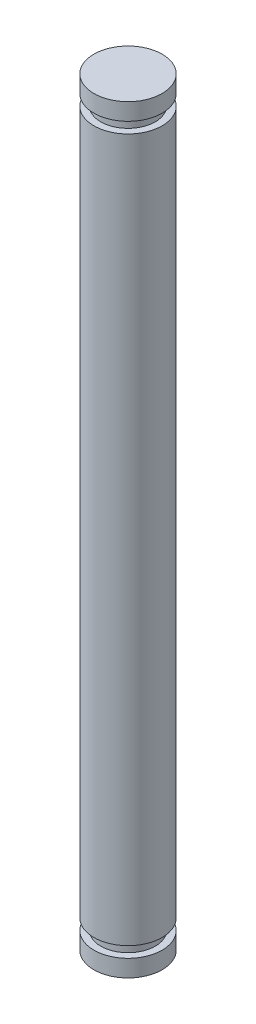
from build123d import *

# Parameters (mm, degrees)
SKETCH1_W   = 2
SKETCH1_H   = 44.5
ESQUISSE1_W = 0.574838605
ESQUISSE1_H = 0.64
ESQUISSE3_W = 1.093459546
ESQUISSE3_H = 0.64


with BuildPart() as part:
    # Sketch1 → Revolve1 (revolve)
    with BuildSketch(Plane.XY):
        with Locations((1, 22.25)):
            Rectangle(SKETCH1_W, SKETCH1_H)
    revolve(axis=Axis((0, 0, 0), (0, 1, 0)))

    # Esquisse1 → Enlèvement de matière-Révolution1 (revolve, cut)
    with BuildSketch(Plane.XY):
        with Locations((1.887419303, 43.18)):
            Rectangle(ESQUISSE1_W, ESQUISSE1_H)
    revolve(axis=Axis((0, 44.5, 0), (0, -1, 0)), mode=Mode.SUBTRACT)

    # Esquisse3 → Enlèvement de matière-Révolution3 (revolve, cut)
    with BuildSketch(Plane.XY):
        with Locations((2.146729773, 1.32)):
            Rectangle(ESQUISSE3_W, ESQUISSE3_H)
    revolve(axis=Axis((0, 44.5, 0), (0, -1, 0)), mode=Mode.SUBTRACT)


solid = part.part
